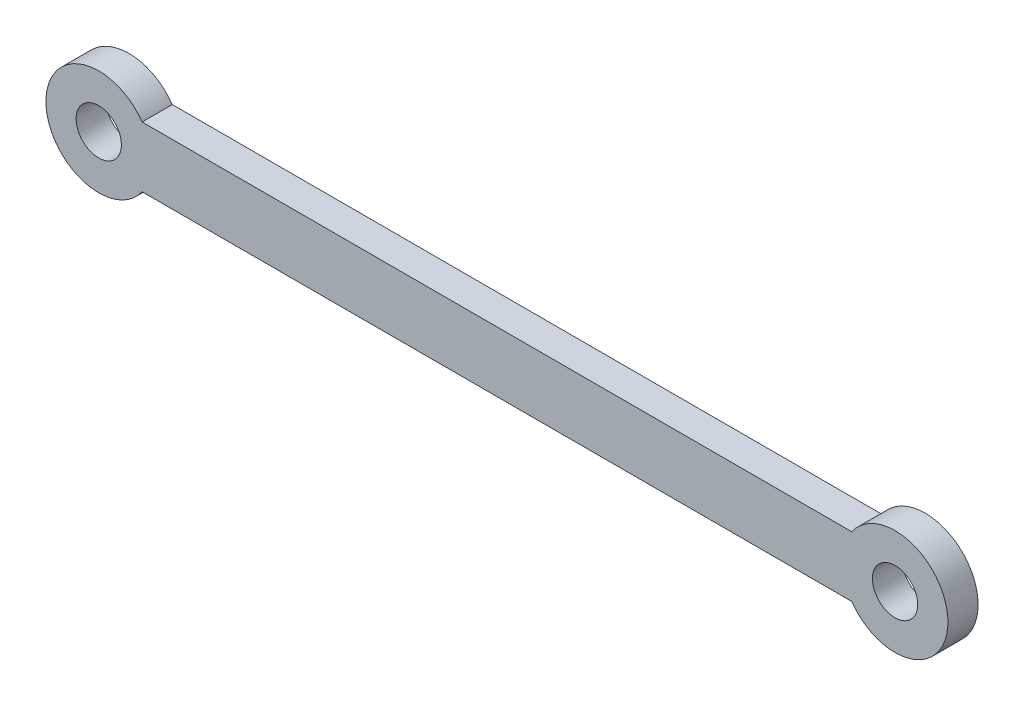
from build123d import *

# Parameters (mm, degrees)
CROQUIS1_R              = 1.5
SALIENTE_EXTRUIR1_DEPTH = 2


with BuildPart() as part:
    # Croquis1 → Saliente-Extruir1 (new body)
    with BuildSketch(Plane.XY):
        with BuildLine():
            ThreePointArc((-22.872281323, 0), (-23.032896303, -1.048097173), (-23.5, -2))
            Line((-23.5, -2), (23.5, -2))
            ThreePointArc((23.5, -2), (22.872281323, 0), (23.5, 2))
            Line((23.5, 2), (-23.5, 2))
            ThreePointArc((-23.5, 2), (-23.032896303, 1.048097173), (-22.872281323, 0))
        make_face()
        with BuildLine():
            ThreePointArc((-23.5, 2), (-29.872281323, 0), (-23.5, -2))
            Line((-23.5, -2), (-23.5, 2))
        make_face()
        with Locations((-26.372281323, 0)):
            Circle(CROQUIS1_R, mode=Mode.SUBTRACT)
        with BuildLine():
            Line((23.5, 2), (23.5, -2))
            ThreePointArc((23.5, -2), (27.420378496, -3.339385021), (29.872281323, 0))
            ThreePointArc((29.872281323, 0), (27.420378496, 3.339385021), (23.5, 2))
        make_face()
        with Locations((26.372281323, 0)):
            Circle(CROQUIS1_R, mode=Mode.SUBTRACT)
        with BuildLine():
            Line((-23.5, 2), (-23.5, -2))
            ThreePointArc((-23.5, -2), (-23.032896303, -1.048097173), (-22.872281323, 0))
            ThreePointArc((-22.872281323, 0), (-23.032896303, 1.048097173), (-23.5, 2))
        make_face()
        with BuildLine():
            ThreePointArc((23.5, 2), (22.872281323, 0), (23.5, -2))
            Line((23.5, -2), (23.5, 2))
        make_face()
    extrude(amount=SALIENTE_EXTRUIR1_DEPTH)


solid = part.part
